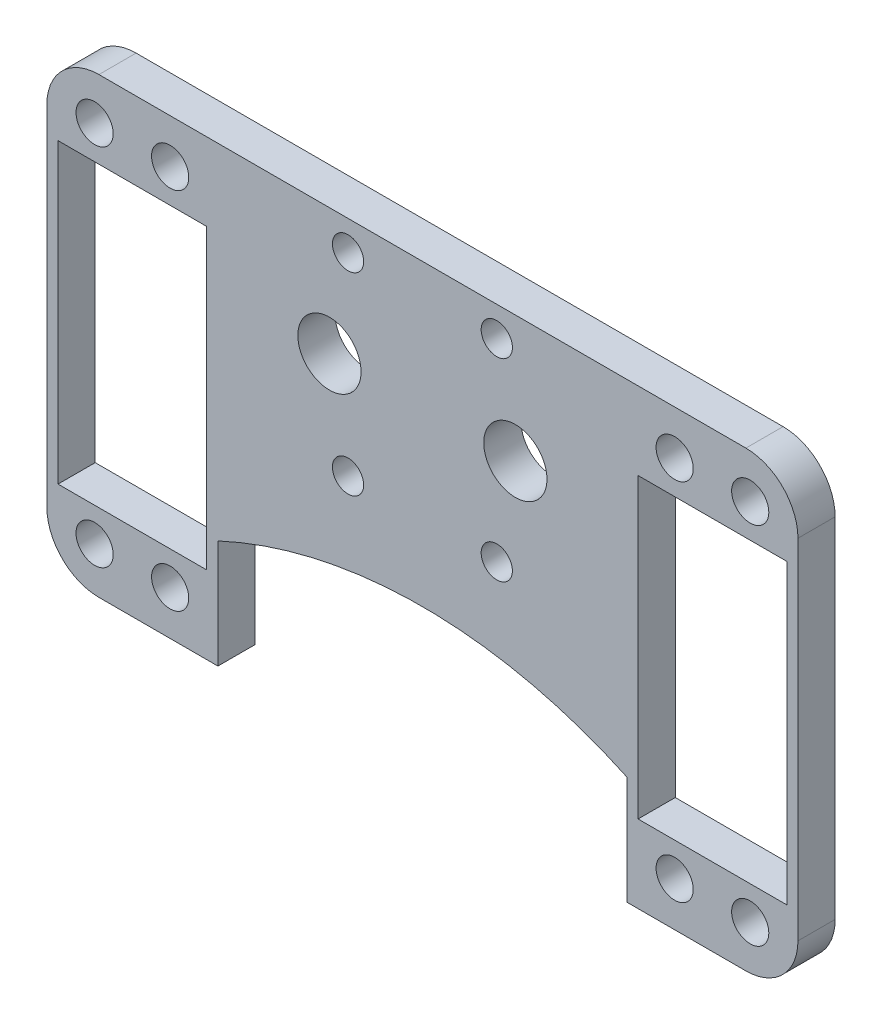
from build123d import *

# Parameters (mm, degrees)
SKETCH1_R           = 2.1
BOSS_EXTRUDE1_DEPTH = 5
CUT_EXTRUDE1_DEPTH  = 5
SKETCH3_W           = 38.251438616
SKETCH3_H           = 32.766065525
CUT_EXTRUDE2_DEPTH  = 10
BOSS_EXTRUDE2_DEPTH = 5
SKETCH5_W           = 101.856885825
SKETCH5_H           = 15.226385752
CUT_EXTRUDE3_DEPTH  = 10
BOSS_EXTRUDE3_DEPTH = 5
CUT_EXTRUDE4_DEPTH  = 5
SKETCH8_R           = 2.5
SKETCH8_W           = 20
SKETCH8_H           = 40
CUT_EXTRUDE5_DEPTH  = 5
FILLET2_R           = 7


with BuildPart() as part:
    # Sketch1 → Boss-Extrude1 (new body)
    with BuildSketch(Plane.XY):
        Polygon((27.058043777, 13.348752177), (18.058043777, 13.348752177), (18.058043777, 18.348752177), (-18.941956223, 18.348752177), (-18.941956223, 13.348752177), (-27.941956223, 13.348752177), (-27.941956223, 1.348752177), (-27.941956223, -10.651247823), (-63.297295282, -46.006586882), (-51.297295282, -58.006586882), (50.413382836, -58.006586882), (62.413382836, -46.006586882), (27.058043777, -10.651247823), (27.058043777, 1.348752177), align=None)
        with Locations((9.558043777, -11.651247823)):
            Circle(SKETCH1_R, mode=Mode.SUBTRACT)
        with Locations((-10.441956223, -11.651247823)):
            Circle(SKETCH1_R, mode=Mode.SUBTRACT)
        with Locations((-10.441956223, 14.348752177)):
            Circle(SKETCH1_R, mode=Mode.SUBTRACT)
        with Locations((9.558043777, 14.348752177)):
            Circle(SKETCH1_R, mode=Mode.SUBTRACT)
        with BuildLine():
            ThreePointArc((-8.691956223, 1.348752177), (-12.941956223, 5.598752177), (-17.191956223, 1.348752177))
            ThreePointArc((-17.191956223, 1.348752177), (-12.941956223, -2.901247823), (-8.691956223, 1.348752177))
        make_face(mode=Mode.SUBTRACT)
        with BuildLine():
            ThreePointArc((16.308043777, 1.348752177), (12.058043777, 5.598752177), (7.808043777, 1.348752177))
            ThreePointArc((7.808043777, 1.348752177), (12.058043777, -2.901247823), (16.308043777, 1.348752177))
        make_face(mode=Mode.SUBTRACT)
    extrude(amount=BOSS_EXTRUDE1_DEPTH)

    # Sketch2 → Cut-Extrude1 (cut)
    with BuildSketch(Plane(origin=(0, 0, 0), x_dir=(-1, 0, 0), z_dir=(0, 0, -1))):
        with BuildLine():
            Line((-27.058043777, -22.48694002), (-27.058043777, -151.230871916))
            ThreePointArc((-27.058043777, -151.230871916), (0.441956223, -156.858905968), (27.941956223, -151.230871916))
            Line((27.941956223, -151.230871916), (27.941956223, -22.48694002))
            ThreePointArc((27.941956223, -22.48694002), (0.441956223, -16.858905968), (-27.058043777, -22.48694002))
        make_face()
    extrude(amount=-CUT_EXTRUDE1_DEPTH, mode=Mode.SUBTRACT)

    # Sketch3 → Cut-Extrude2 (cut)
    with BuildSketch(Plane(origin=(0, 0, 0), x_dir=(-1, 0, 0), z_dir=(0, 0, -1))):
        with Locations((-46.183763085, -43.921177391)):
            Rectangle(SKETCH3_W, SKETCH3_H)
        with Locations((47.067675531, -43.921177391)):
            Rectangle(SKETCH3_W, SKETCH3_H)
    extrude(amount=-CUT_EXTRUDE2_DEPTH, mode=Mode.SUBTRACT)

    # Sketch4 → Boss-Extrude2 (add)
    with BuildSketch(Plane(origin=(0, 0, 0), x_dir=(-1, 0, 0), z_dir=(0, 0, -1))):
        with BuildLine():
            Line((27.941956223, -10.651247823), (44.828853028, -27.538144628))
            Line((44.828853028, -27.538144628), (50.941956223, -27.538144628))
            Line((50.941956223, -27.538144628), (50.941956223, 27.461855372))
            ThreePointArc((50.941956223, 27.461855372), (49.477490129, 30.997389278), (45.941956223, 32.461855372))
            Line((45.941956223, 32.461855372), (-45.058043777, 32.461855372))
            ThreePointArc((-45.058043777, 32.461855372), (-48.593577683, 30.997389278), (-50.058043777, 27.461855372))
            Line((-50.058043777, 27.461855372), (-50.058043777, -27.538144628))
            Line((-50.058043777, -27.538144628), (-43.944940582, -27.538144628))
            Line((-43.944940582, -27.538144628), (-27.058043777, -10.651247823))
            Line((-27.058043777, -10.651247823), (-27.058043777, 13.348752177))
            Line((-27.058043777, 13.348752177), (-18.058043777, 13.348752177))
            Line((-18.058043777, 13.348752177), (-18.058043777, 18.348752177))
            Line((-18.058043777, 18.348752177), (18.941956223, 18.348752177))
            Line((18.941956223, 18.348752177), (18.941956223, 13.348752177))
            Line((18.941956223, 13.348752177), (27.941956223, 13.348752177))
            Line((27.941956223, 13.348752177), (27.941956223, -10.651247823))
        make_face()
    extrude(amount=-BOSS_EXTRUDE2_DEPTH)

    # Sketch5 → Cut-Extrude3 (cut)
    with BuildSketch(Plane.XY.offset(5)):
        with Locations((-0.013513311, 25.961945053)):
            Rectangle(SKETCH5_W, SKETCH5_H)
    extrude(amount=-CUT_EXTRUDE3_DEPTH, mode=Mode.SUBTRACT)

    # Sketch6 → Boss-Extrude3 (add)
    with BuildSketch(Plane.XY.offset(5)):
        with BuildLine():
            Line((50.058043777, -27.538144628), (27.058043777, -27.538144628))
            Line((27.058043777, -27.538144628), (27.058043777, -22.48694002))
            ThreePointArc((27.058043777, -22.48694002), (-0.441956223, -16.858905968), (-27.941956223, -22.48694002))
            Line((-27.941956223, -22.48694002), (-27.941956223, -27.538144628))
            Line((-27.941956223, -27.538144628), (-50.941956223, -27.538144628))
            Line((-50.941956223, -27.538144628), (-50.941956223, -42.538144628))
            Line((-50.941956223, -42.538144628), (-12.941956223, -42.538144628))
            Line((-12.941956223, -42.538144628), (12.058043777, -42.538144628))
            Line((12.058043777, -42.538144628), (50.058043777, -42.538144628))
            Line((50.058043777, -42.538144628), (50.058043777, -27.538144628))
        make_face()
    extrude(amount=-BOSS_EXTRUDE3_DEPTH)

    # Sketch7 → Cut-Extrude4 (cut)
    with BuildSketch(Plane.XY.offset(5)):
        with BuildLine():
            Line((-27.941956223, -27.962811021), (-27.941956223, -42.538144628))
            Line((-27.941956223, -42.538144628), (27.058043777, -42.538144628))
            Line((27.058043777, -42.538144628), (27.058043777, -27.962811021))
            ThreePointArc((27.058043777, -27.962811021), (-0.441956223, -21.858905968), (-27.941956223, -27.962811021))
        make_face()
    extrude(amount=-CUT_EXTRUDE4_DEPTH, mode=Mode.SUBTRACT)

    # Sketch8 → Cut-Extrude5 (cut)
    with BuildSketch(Plane(origin=(0, 0, 0), x_dir=(-1, 0, 0), z_dir=(0, 0, -1))):
        with Locations((44.521956223, 12.405303775)):
            Circle(SKETCH8_R)
        with Locations((34.361956223, 12.405303775)):
            Circle(SKETCH8_R)
        with Locations((34.361956223, -36.594696225)):
            Circle(SKETCH8_R)
        with Locations((44.521956223, -36.594696225)):
            Circle(SKETCH8_R)
        with Locations((-43.638043777, -36.594696225)):
            Circle(SKETCH8_R)
        with Locations((-33.478043777, -36.594696225)):
            Circle(SKETCH8_R)
        with Locations((-33.478043777, 12.405303775)):
            Circle(SKETCH8_R)
        with Locations((-43.638043777, 12.405303775)):
            Circle(SKETCH8_R)
        with Locations((39.441956223, -12.094696225)):
            Rectangle(SKETCH8_W, SKETCH8_H)
        with Locations((-38.558043777, -12.094696225)):
            Rectangle(SKETCH8_W, SKETCH8_H)
    extrude(amount=-CUT_EXTRUDE5_DEPTH, mode=Mode.SUBTRACT)

    # Fillet2
    fillet2_edges = [part.edges().sort_by_distance(p)[0] for p in [
        (50.058043777, 18.348752177, 2.5),
        (-50.941956223, 18.348752177, 2.5),
        (50.058043777, -42.538144628, 2.5),
        (-50.941956223, -42.538144628, 2.5),
    ]]
    fillet(fillet2_edges, radius=FILLET2_R)


solid = part.part
